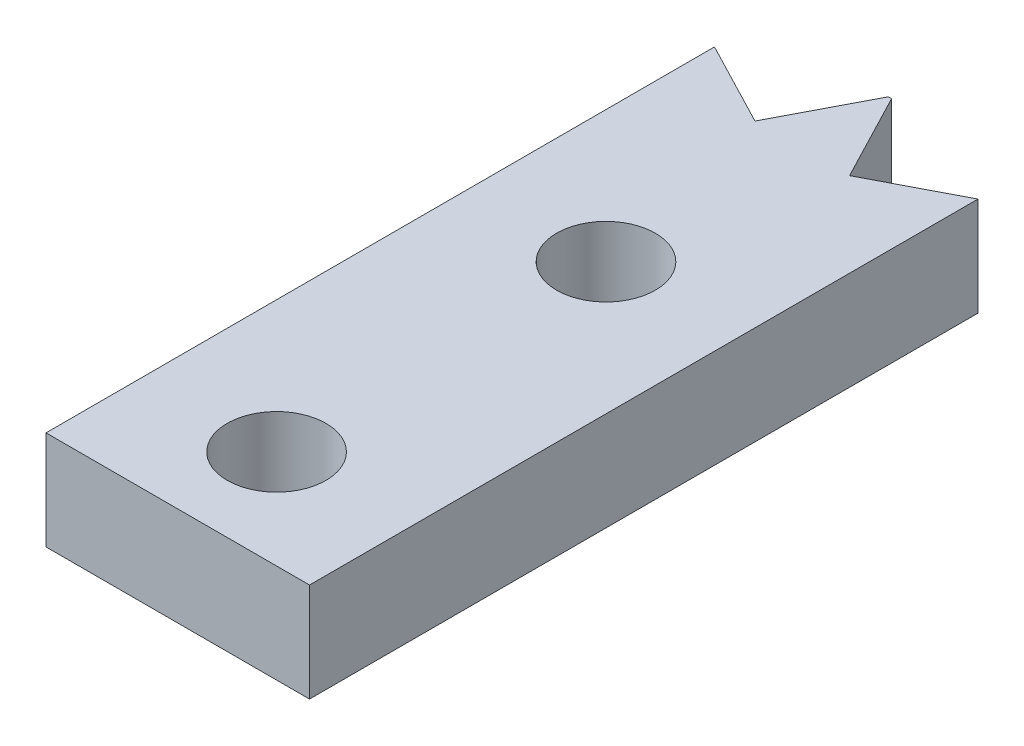
from build123d import *

# Parameters (mm, degrees)
BOSS_EXTRUDE3_DEPTH      = 3
M3_CLEARANCE_HOLE1_D     = 3
M3_CLEARANCE_HOLE1_DEPTH = 10
M3_CLEARANCE_HOLE1_TIP   = 0.901290929
SKETCH5_W                = 0.5
SKETCH5_H                = 21.724414851
CUT_EXTRUDE1_DEPTH       = 10
SKETCH6_W                = 8
SKETCH6_H                = 3
CUT_EXTRUDE2_DEPTH       = 1.38


with BuildPart() as part:
    # Sketch1 → Boss-Extrude3 (new body)
    with BuildSketch(Plane(origin=(0, 0, 0), x_dir=(1, 0, 0), z_dir=(0, 1, 0))):
        Polygon((5.303721661, 23.00020151), (5.253721661, 23.00020151), (5.253721661, 0), (9.753721661, 0), (9.753721661, 21.724414851), (9.35, 21.724414851), (6.6889675, 20.339169011), align=None)
        Polygon((3.818475821, 20.339169011), (1.157443322, 21.724414851), (0.753721661, 21.724414851), (0.753721661, 0), (5.253721661, 0), (5.253721661, 23.00020151), (5.203721661, 23.00020151), align=None)
    extrude(amount=BOSS_EXTRUDE3_DEPTH)

    # M3 Clearance Hole1
    with Locations(Plane(origin=(5.253721661, 3, -14.38), x_dir=(0, 0, 1), z_dir=(0, 1, 0))):
        with Locations((0, 0), (10, 0)):
            Hole(M3_CLEARANCE_HOLE1_D / 2, depth=M3_CLEARANCE_HOLE1_DEPTH)
            with Locations((0, 0, -(M3_CLEARANCE_HOLE1_DEPTH + M3_CLEARANCE_HOLE1_TIP / 2))):  # 118° drill point
                Cone(0, M3_CLEARANCE_HOLE1_D / 2, M3_CLEARANCE_HOLE1_TIP, mode=Mode.SUBTRACT)

    # Sketch5 → Cut-Extrude1 (cut)
    with BuildSketch(Plane(origin=(0, 0, 0), x_dir=(-1, 0, 0), z_dir=(0, -1, 0))):
        with Locations((-1.003721661, 10.862207426)):
            Rectangle(SKETCH5_W, SKETCH5_H)
        with Locations((-9.503721661, 10.862207426)):
            Rectangle(SKETCH5_W, SKETCH5_H)
    extrude(amount=-CUT_EXTRUDE1_DEPTH, mode=Mode.SUBTRACT)

    # Sketch6 → Cut-Extrude2 (cut)
    with BuildSketch(Plane.XY):
        with Locations((5.253721661, 1.5)):
            Rectangle(SKETCH6_W, SKETCH6_H)
    extrude(amount=-CUT_EXTRUDE2_DEPTH, mode=Mode.SUBTRACT)


solid = part.part
